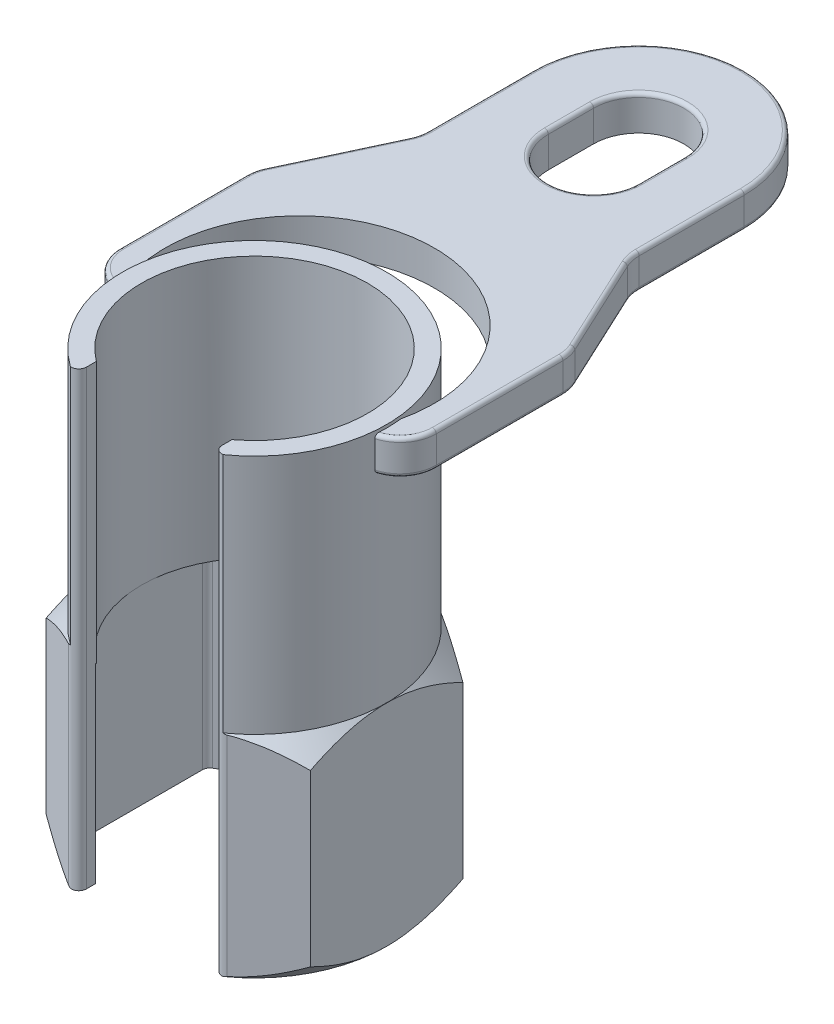
from build123d import *
from build123d.topology import SkipClean

# Parameters (mm, degrees)
EXTRUDE1_DEPTH     = 28
EXTRUDE2_DEPTH     = 32
SKETCH8_OUTSIDE_W  = 174.664
SKETCH8_OUTSIDE_H  = 174.894
SKETCH8_OUTSIDE_R  = 17.537014427
CUT_EXTRUDE4_DEPTH = 61
CUT_EXTRUDE4_DRAFT = -45
SKETCH19_OUTSIDE_W = 110.664
SKETCH19_OUTSIDE_H = 110.894
SKETCH19_OUTSIDE_R = 17.536914427
CUT_EXTRUDE6_DEPTH = 29
CUT_EXTRUDE6_DRAFT = -45
CUT_EXTRUDE9_START = -25.286914
CUT_EXTRUDE9_DEPTH = 25.286914
FILLET1_R          = 1
EXTRUDE7_DEPTH     = 4.6
CUT_EXTRUDE8_REACH = 61.6
FILLET4_R          = 0.5


with BuildPart() as part:
    # Sketch1 → Extrude1 (new body)
    with BuildSketch(Plane(origin=(0, 0, 0), x_dir=(1, 0, 0), z_dir=(0, 1, 0))):
        with BuildLine():
            Line((-9, -12), (-9, -15.053847577))
            Line((-9, -15.053847577), (-17.537014427, -10.125))
            Line((-17.537014427, -10.125), (-17.537014427, 10.125))
            Line((-17.537014427, 10.125), (0, 20.25))
            Line((0, 20.25), (17.537014427, 10.125))
            Line((17.537014427, 10.125), (17.537014427, -10.125))
            Line((17.537014427, -10.125), (9, -15.053847577))
            Line((9, -15.053847577), (9, -12))
            ThreePointArc((9, -12), (0, 15), (-9, -12))
        make_face()
    extrude(amount=EXTRUDE1_DEPTH)

    # Sketch3 → Extrude2 (add)
    with BuildSketch(Plane(origin=(0, 28, 0), x_dir=(-1, 0, 0), z_dir=(0, 1, 0))):
        with BuildLine():
            Line((-9, 15.051357667), (-9, 12))
            ThreePointArc((-9, 12), (0, -15), (9, 12))
            Line((9, 12), (9, 15.051357667))
            ThreePointArc((9, 15.051357667), (0, -17.536914427), (-9, 15.051357667))
        make_face()
    extrude(amount=EXTRUDE2_DEPTH)


with BuildPart() as cut_extrude4_tool:
    # Sketch8 outside → Cut-Extrude4 (with draft: the straight prism first)
    with BuildSketch(Plane.XZ):
        with Locations((0, -2.598)):
            Rectangle(SKETCH8_OUTSIDE_W, SKETCH8_OUTSIDE_H)
        Circle(SKETCH8_OUTSIDE_R, mode=Mode.SUBTRACT)
    extrude(amount=-CUT_EXTRUDE4_DEPTH)
    # Cut-Extrude4: the draft: its side faces are tilted about the plane it starts from
    cut_extrude4_sides = [cut_extrude4_tool.faces().sort_by_distance(p)[0] for p in [
        (0, 30.5, -90.045),
        (87.332, 30.5, -2.598),
        (0, 30.5, 84.849),
        (-87.332, 30.5, -2.598),
        (-17.537014427, 30.5, 0),
    ]]
    draft(cut_extrude4_sides, Plane.XZ, CUT_EXTRUDE4_DRAFT)


with BuildPart() as part_1:
    add(part.part)

    # Cut-Extrude4: cut by cut_extrude4_tool
    add(cut_extrude4_tool.part, mode=Mode.SUBTRACT)


with BuildPart() as cut_extrude6_tool:
    # Sketch19 outside → Cut-Extrude6 (with draft: the straight prism first)
    with BuildSketch(Plane(origin=(0, 28, 0), x_dir=(-1, 0, 0), z_dir=(0, 1, 0))):
        with Locations((0, -2.598)):
            Rectangle(SKETCH19_OUTSIDE_W, SKETCH19_OUTSIDE_H)
        Circle(SKETCH19_OUTSIDE_R, mode=Mode.SUBTRACT)
    extrude(amount=-CUT_EXTRUDE6_DEPTH)
    # Cut-Extrude6: the draft: its side faces are tilted about the plane it starts from
    cut_extrude6_sides = [cut_extrude6_tool.faces().sort_by_distance(p)[0] for p in [
        (0, 13.5, -58.045),
        (-55.332, 13.5, -2.598),
        (0, 13.5, 52.849),
        (55.332, 13.5, -2.598),
        (17.536914427, 13.5, 0),
    ]]
    draft(cut_extrude6_sides, Plane(origin=(0, 28, 0), x_dir=(-1, 0, 0), z_dir=(0, 1, 0)), CUT_EXTRUDE6_DRAFT)


with BuildPart() as part_2:
    add(part_1.part)

    # Cut-Extrude6: cut by cut_extrude6_tool
    add(cut_extrude6_tool.part, mode=Mode.SUBTRACT)

    # Sketch26 → Cut-Extrude9 (cut)
    with BuildSketch(Plane.XZ.offset(CUT_EXTRUDE9_START)):
        Polygon((-15, -8.660254038), (0, -17.320508076), (15, -8.660254038), (15, 8.660254038), (0, 17.320508076), (-15, 8.660254038), align=None)
    extrude(amount=CUT_EXTRUDE9_DEPTH, mode=Mode.SUBTRACT)

    # Fillet1
    fillet1_edges = [part_2.edges().sort_by_distance(p)[0] for p in [
        (-15, 12.643457, -8.660254038),
        (-15, 12.643457, 8.660254038),
        (15, 12.643457, 8.660254038),
        (15, 12.643457, -8.660254038),
        (-9, 13.99995, 15.053847577),
        (9, 13.99995, 15.053847577),
        (0, 12.643457, -17.320508076),
    ]]
    fillet(fillet1_edges, radius=FILLET1_R)

    # Sketch16 → Extrude7 (add)
    with BuildSketch(Plane(origin=(0, 55, 0), x_dir=(-1, 0, 0), z_dir=(0, 1, 0))):
        with BuildLine():
            Line((-14, -51), (-14, -37.064876816))
            ThreePointArc((-14, -37.064876816), (-14.113932376, -36.025275822), (-14.450320928, -35.035026583))
            Line((-14.450320928, -35.035026583), (-20.549679072, -21.964973417))
            ThreePointArc((-20.549679072, -21.964973417), (-20.886067624, -20.974724178), (-21, -19.935123184))
            Line((-21, -19.935123184), (-21, -3.128214718))
            ThreePointArc((-21, -3.128214718), (-20.01763684, -0.21863589), (-17.472646268, 1.5))
            ThreePointArc((-17.472646268, 1.5), (0, -17.536914427), (17.472646268, 1.5))
            ThreePointArc((17.472646268, 1.5), (20.01763684, -0.21863589), (21, -3.128214718))
            Line((21, -3.128214718), (21, -19.935123184))
            ThreePointArc((21, -19.935123184), (20.886067624, -20.974724178), (20.549679072, -21.964973417))
            Line((20.549679072, -21.964973417), (14.450320928, -35.035026583))
            ThreePointArc((14.450320928, -35.035026583), (14.113932376, -36.025275822), (14, -37.064876816))
            Line((14, -37.064876816), (14, -51))
            ThreePointArc((14, -51), (0, -65), (-14, -51))
        make_face()
    extrude(amount=EXTRUDE7_DEPTH)

    # Sketch25 → Cut-Extrude8 (cut, up to next)
    with BuildSketch(Plane.XZ.offset(-59.6), mode=Mode.PRIVATE) as cut_extrude8_sk1:
        with BuildLine():
            Line((-6, -51), (-6, -45))
            ThreePointArc((-6, -45), (0, -39), (6, -45))
            Line((6, -45), (6, -51))
            ThreePointArc((6, -51), (0, -57), (-6, -51))
        make_face()
    cut_extrude8_tool1 = extrude(cut_extrude8_sk1.sketch, amount=CUT_EXTRUDE8_REACH, mode=Mode.PRIVATE) & part_2.part
    add(cut_extrude8_tool1.solids().sort_by_distance((0, 59.6, -48))[0], mode=Mode.SUBTRACT)
    # Sketch25 → Cut-Extrude8 (cut, up to next)
    with BuildSketch(Plane.XZ.offset(-59.6), mode=Mode.PRIVATE) as cut_extrude8_sk2:
        with BuildLine():
            ThreePointArc((17.422496021, -2), (0, -17.536914427), (-17.422496021, -2))
            ThreePointArc((-17.422496021, -2), (0, -23.875776), (17.422496021, -2))
        make_face()
    cut_extrude8_tool2 = extrude(cut_extrude8_sk2.sketch, amount=CUT_EXTRUDE8_REACH, mode=Mode.PRIVATE) & part_2.part
    add(cut_extrude8_tool2.solids().sort_by_distance((0, 59.6, -17.956047))[0], mode=Mode.SUBTRACT)

    # Fillet4
    fillet4_edges = [part_2.edges().sort_by_distance(p)[0] for p in [
        (-20.01763684, 55, -0.21863589),
        (20.01763684, 55, -0.21863589),
        (21, 55, -11.531668951),
        (20.886067624, 55, -20.974724178),
        (17.5, 55, -28.5),
        (14.113932376, 55, -36.025275822),
        (14, 55, -44.032438408),
        (0, 55, -65),
        (-14, 55, -44.032438408),
        (-14.113932376, 55, -36.025275822),
        (-17.5, 55, -28.5),
        (-20.886067624, 55, -20.974724178),
        (-21, 55, -11.531668951),
        (-20.01763684, 59.6, -0.21863589),
        (20.01763684, 59.6, -0.21863589),
        (21, 59.6, -11.531668951),
        (20.886067624, 59.6, -20.974724178),
        (17.5, 59.6, -28.5),
        (14.113932376, 59.6, -36.025275822),
        (14, 59.6, -44.032438408),
        (0, 59.6, -65),
        (-14, 59.6, -44.032438408),
        (-14.113932376, 59.6, -36.025275822),
        (-17.5, 59.6, -28.5),
        (-20.886067624, 59.6, -20.974724178),
        (-21, 59.6, -11.531668951),
        (0, 59.6, -57),
        (6, 59.6, -48),
        (0, 59.6, -39),
        (-6, 59.6, -48),
    ]]
    fillet(fillet4_edges, radius=FILLET4_R)


solid = part_2.part
